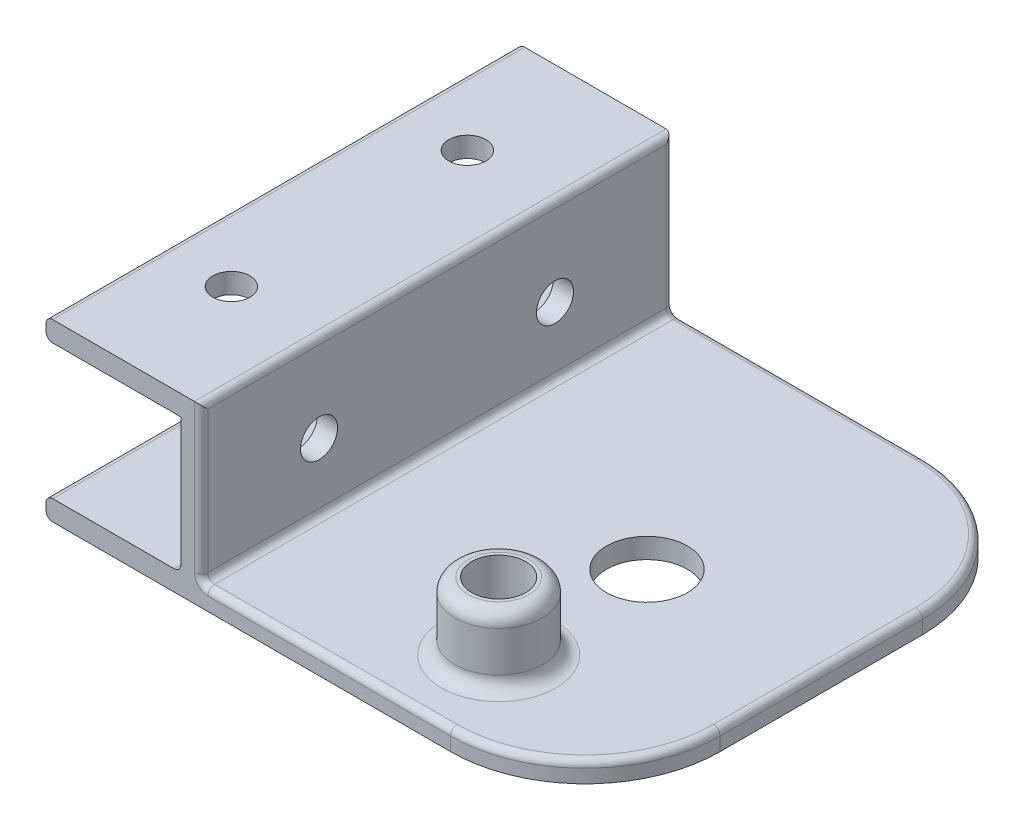
from build123d import *

# Parameters (mm, degrees)
SKETCH1_W                = 20
SKETCH1_H                = 70
SKETCH1_R                = 2.5
SKETCH1_W_2              = 57
SKETCH1_W_3              = 3
BOSS_EXTRUDE1_DEPTH      = 3
SKETCH1_3_W              = 3
SKETCH1_3_H              = 70
BOSS_EXTRUDE2_DEPTH      = 26
SKETCH3_R                = 11.0045
SKETCH3_R_2              = 6
CUT_EXTRUDE2_DEPTH       = 10
FILLET1_R                = 20
BOSS_EXTRUDE4_START      = 26
SKETCH1_4_W              = 20
SKETCH1_4_H              = 70
SKETCH1_4_R              = 2.5
BOSS_EXTRUDE4_DEPTH      = 3
SKETCH4_R                = 6.5
SKETCH4_R_2              = 4
BOSS_EXTRUDE5_DEPTH      = 10
FILLET2_R                = 1
SKETCH3_4_R              = 11.0045
SKETCH3_4_R_2            = 6
BOSS_EXTRUDE7_DEPTH      = 3
FILLET3_R                = 2
M5_CLEARANCE_HOLE1_D     = 5.5
M5_CLEARANCE_HOLE1_DEPTH = 23
M5_CLEARANCE_HOLE2_D     = 5.5


with BuildPart() as part:
    # Sketch1 → Boss-Extrude1 (new body)
    with BuildSketch(Plane(origin=(0, 0, 0), x_dir=(1, 0, 0), z_dir=(0, 1, 0))):
        with Locations((-30, 0)):
            Rectangle(SKETCH1_W, SKETCH1_H)
        with Locations((-30, -17.5)):
            Circle(SKETCH1_R, mode=Mode.SUBTRACT)
        with Locations((-30, 17.5)):
            Circle(SKETCH1_R, mode=Mode.SUBTRACT)
        with Locations((11.5, 0)):
            Rectangle(SKETCH1_W_2, SKETCH1_H)
        with Locations((-18.5, 0)):
            Rectangle(SKETCH1_W_3, SKETCH1_H)
    extrude(amount=BOSS_EXTRUDE1_DEPTH)

    # Sketch1_3 → Boss-Extrude2 (add)
    with BuildSketch(Plane(origin=(0, 0, 0), x_dir=(1, 0, 0), z_dir=(0, 1, 0))):
        with Locations((-18.5, 0)):
            Rectangle(SKETCH1_3_W, SKETCH1_3_H)
    extrude(amount=BOSS_EXTRUDE2_DEPTH)

    # Sketch3 → Cut-Extrude2 (cut)
    with BuildSketch(Plane(origin=(0, 3, 0), x_dir=(1, 0, 0), z_dir=(0, 1, 0))):
        with Locations((14.15, 0)):
            Circle(SKETCH3_R)
        with Locations((14.15, 0)):
            Circle(SKETCH3_R_2)
    extrude(amount=-CUT_EXTRUDE2_DEPTH, mode=Mode.SUBTRACT)

    # Fillet1
    fillet1_edges = [part.edges().sort_by_distance(p)[0] for p in [
        (40, 1.5, -35),
        (40, 1.5, 35),
    ]]
    fillet(fillet1_edges, radius=FILLET1_R)

    # Sketch1_4 → Boss-Extrude4 (add)
    with BuildSketch(Plane(origin=(0, 0, 0), x_dir=(1, 0, 0), z_dir=(0, 1, 0)).offset(BOSS_EXTRUDE4_START)):
        with Locations((-30, 0)):
            Rectangle(SKETCH1_4_W, SKETCH1_4_H)
        with Locations((-30, -17.5)):
            Circle(SKETCH1_4_R, mode=Mode.SUBTRACT)
        with Locations((-30, 17.5)):
            Circle(SKETCH1_4_R, mode=Mode.SUBTRACT)
    extrude(amount=-BOSS_EXTRUDE4_DEPTH)

    # Sketch4 → Boss-Extrude5 (add)
    with BuildSketch(Plane(origin=(0, 3, 0), x_dir=(1, 0, 0), z_dir=(0, 1, 0))):
        with Locations((14.15, -22)):
            Circle(SKETCH4_R)
        with Locations((14.15, -22)):
            Circle(SKETCH4_R_2, mode=Mode.SUBTRACT)
    extrude(amount=BOSS_EXTRUDE5_DEPTH)

    # Fillet2
    fillet2_edges = [part.edges().sort_by_distance(p)[0] for p in [
        (1.5, 3, 35),
        (1.5, 3, -35),
        (-20, 3, 0),
        (-17, 14.5, 35),
        (-17, 3, 0),
        (-17, 26, 0),
        (-17, 14.5, -35),
        (-40, 3, 0),
        (40, 3, 0),
        (34.142135624, 3, -29.142135624),
        (34.142135624, 3, 29.142135624),
        (-40, 23, 0),
        (-40, 26, 0),
        (-40, 0, 0),
    ]]
    fillet(fillet2_edges, radius=FILLET2_R)

    # Sketch3_4 → Boss-Extrude7 (add)
    with BuildSketch(Plane(origin=(0, 3, 0), x_dir=(1, 0, 0), z_dir=(0, 1, 0))):
        with Locations((14.15, 0)):
            Circle(SKETCH3_4_R)
        with Locations((14.15, 0)):
            Circle(SKETCH3_4_R_2, mode=Mode.SUBTRACT)
    extrude(amount=-BOSS_EXTRUDE7_DEPTH)

    # Fillet3
    fillet3_edges = [part.edges().sort_by_distance(p)[0] for p in [
        (7.65, 13, 22),
        (7.65, 3, 22),
    ]]
    fillet(fillet3_edges, radius=FILLET3_R)

    # M5 Clearance Hole1
    with Locations(Plane(origin=(-17, 0, 0), x_dir=(0, 0, -1), z_dir=(1, 0, 0))):
        with Locations((-17.5, 13), (17.5, 13)):
            Hole(M5_CLEARANCE_HOLE1_D / 2, depth=M5_CLEARANCE_HOLE1_DEPTH)

    # M5 Clearance Hole2 (through all)
    with Locations(Plane(origin=(0, 26, 0), x_dir=(1, 0, 0), z_dir=(0, 1, 0))):
        with Locations((-30, -17.5), (-30, 17.5)):
            Hole(M5_CLEARANCE_HOLE2_D / 2)


solid = part.part
